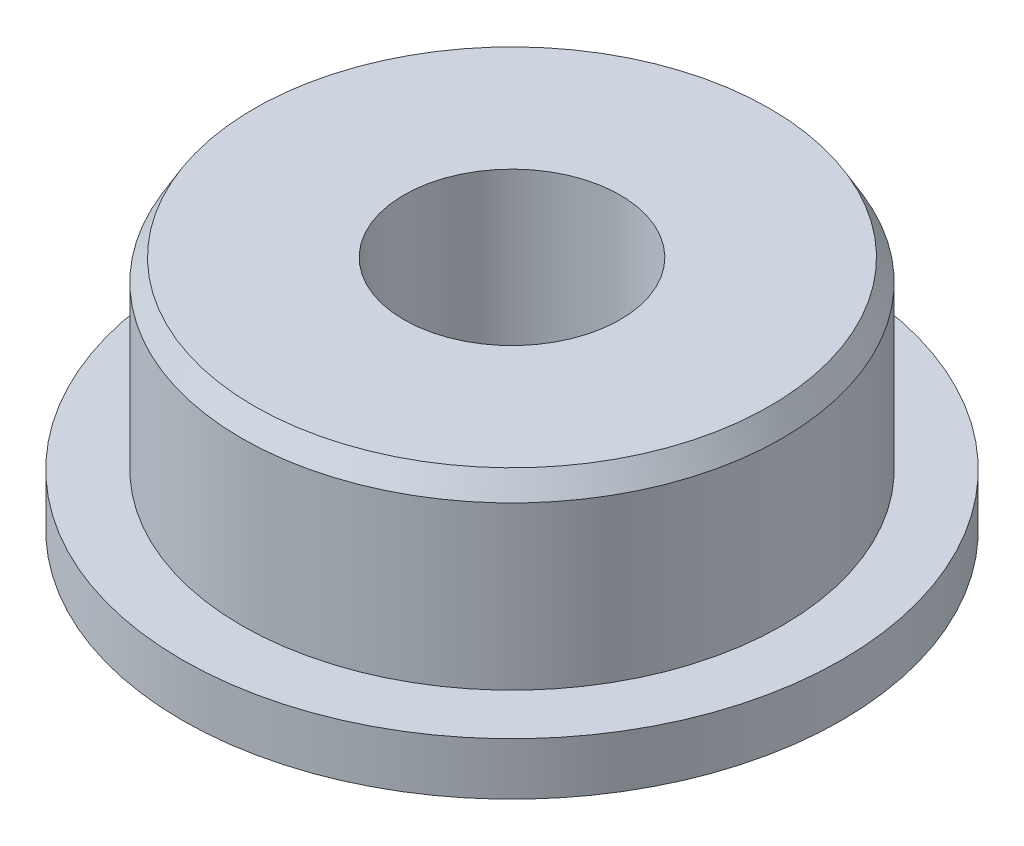
from build123d import *

# Parameters (mm, degrees)
SKETCH_1_R             = 2.5
SKETCH_1_R_2           = 1
EXTRUDE_1_DEPTH        = 2.3
SKETCH_1_3_R           = 3.05
SKETCH_1_3_R_2         = 2.5
EXTRUDE_2_DEPTH        = 0.6
CHAMFER_1_SIZE         = 0.2
CHAMFER_1_SIZE2        = 0.115470054
CHAMFER_1_PART_2_SIZE  = 0.2
CHAMFER_1_PART_2_SIZE2 = 0.115470054


with BuildPart() as part:
    # Sketch 1 → Extrude 1 (new body)
    with BuildSketch(Plane(origin=(0, 0, 0), x_dir=(1, 0, 0), z_dir=(0, 1, 0))):
        Circle(SKETCH_1_R)
        Circle(SKETCH_1_R_2, mode=Mode.SUBTRACT)
    extrude(amount=EXTRUDE_1_DEPTH)

    # Sketch 1_3 → Extrude 2 (add)
    with BuildSketch(Plane(origin=(0, 0, 0), x_dir=(1, 0, 0), z_dir=(0, 1, 0))):
        Circle(SKETCH_1_3_R)
        Circle(SKETCH_1_3_R_2, mode=Mode.SUBTRACT)
    extrude(amount=EXTRUDE_2_DEPTH)

    # Chamfer 1
    chamfer_1_edges = [part.edges().sort_by_distance(p)[0] for p in [
        (-2.5, 2.3, 0),
    ]]
    chamfer_1_side = [part.faces().sort_by_distance(p)[0] for p in [
        (-2.5, 1.45, 0),
    ]]
    chamfer(chamfer_1_edges, length=CHAMFER_1_SIZE, length2=CHAMFER_1_SIZE2, reference=chamfer_1_side[0])

    # Chamfer 1 part 2
    chamfer_1_part_2_edges = [part.edges().sort_by_distance(p)[0] for p in [
        (-3.05, 0, 0),
    ]]
    chamfer_1_part_2_side = [part.faces().sort_by_distance(p)[0] for p in [
        (-2.963732973, 0, 0),
    ]]
    chamfer(chamfer_1_part_2_edges, length=CHAMFER_1_PART_2_SIZE, length2=CHAMFER_1_PART_2_SIZE2, reference=chamfer_1_part_2_side[0])


solid = part.part
